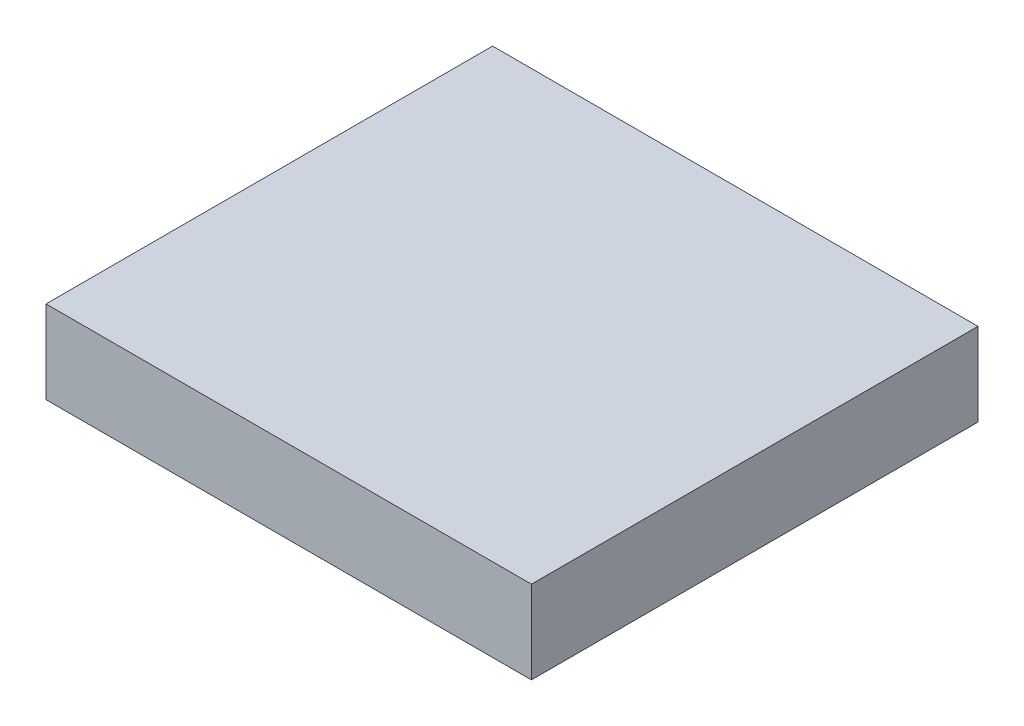
from build123d import *

# Parameters (mm, degrees)
SKETCH3_W           = 31.75
SKETCH3_H           = 29.21
BOSS_EXTRUDE2_DEPTH = 5.4229
CUT_EXTRUDE1_DEPTH  = 0.8636


with BuildPart() as part:
    # Sketch3 → Boss-Extrude2 (new body)
    with BuildSketch(Plane(origin=(0, 0, 0), x_dir=(1, 0, 0), z_dir=(0, 1, 0))):
        Rectangle(SKETCH3_W, SKETCH3_H)
    extrude(amount=BOSS_EXTRUDE2_DEPTH)

    # Sketch1 → Cut-Extrude1 (cut)
    with BuildSketch(Plane(origin=(0, 0, 0), x_dir=(1, 0, 0), z_dir=(0, 1, 0))):
        with BuildLine():
            Line((11.967686493, 5.588), (11.967686493, -5.588))
            ThreePointArc((11.967686493, -5.588), (-13.208, 0), (11.967686493, 5.588))
        make_face()
    extrude(amount=CUT_EXTRUDE1_DEPTH, mode=Mode.SUBTRACT)


solid = part.part
